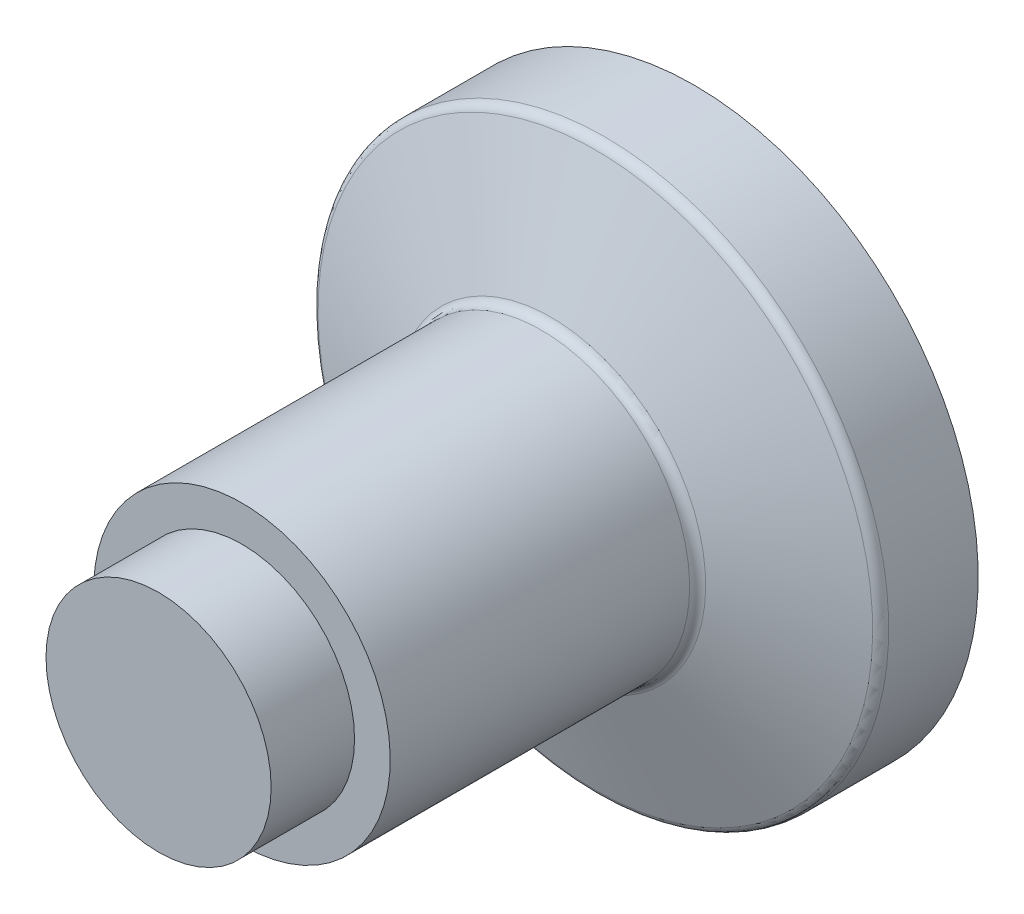
from build123d import *


with BuildPart() as part:
    # Sketch1 → Revolve1 (revolve)
    with BuildSketch(Plane(origin=(0, 0, 0), x_dir=(0, 0, -1), z_dir=(1, 0, 0))):
        with BuildLine():
            Line((39.02588692, 15.407979857), (43.460514917, 27.592020143))
            ThreePointArc((43.460514917, 27.592020143), (43.826631102, 28.069152044), (44.400207538, 28.25))
            Line((44.400207538, 28.25), (53.3, 28.25))
            Line((53.3, 28.25), (53.3, 24.25))
            ThreePointArc((53.3, 24.25), (58.661988488, 12.648147098), (60.5, 0))
            Line((60.5, 0), (0, 0))
            Line((0, 0), (0, 11.2))
            Line((0, 11.2), (8.3, 11.2))
            Line((8.3, 11.2), (8.3, 14.75))
            Line((8.3, 14.75), (38.086194299, 14.75))
            ThreePointArc((38.086194299, 14.75), (38.659770736, 14.930847956), (39.02588692, 15.407979857))
        make_face()
    revolve(axis=Axis((0, 0, 0), (0, 0, -1)))


solid = part.part
